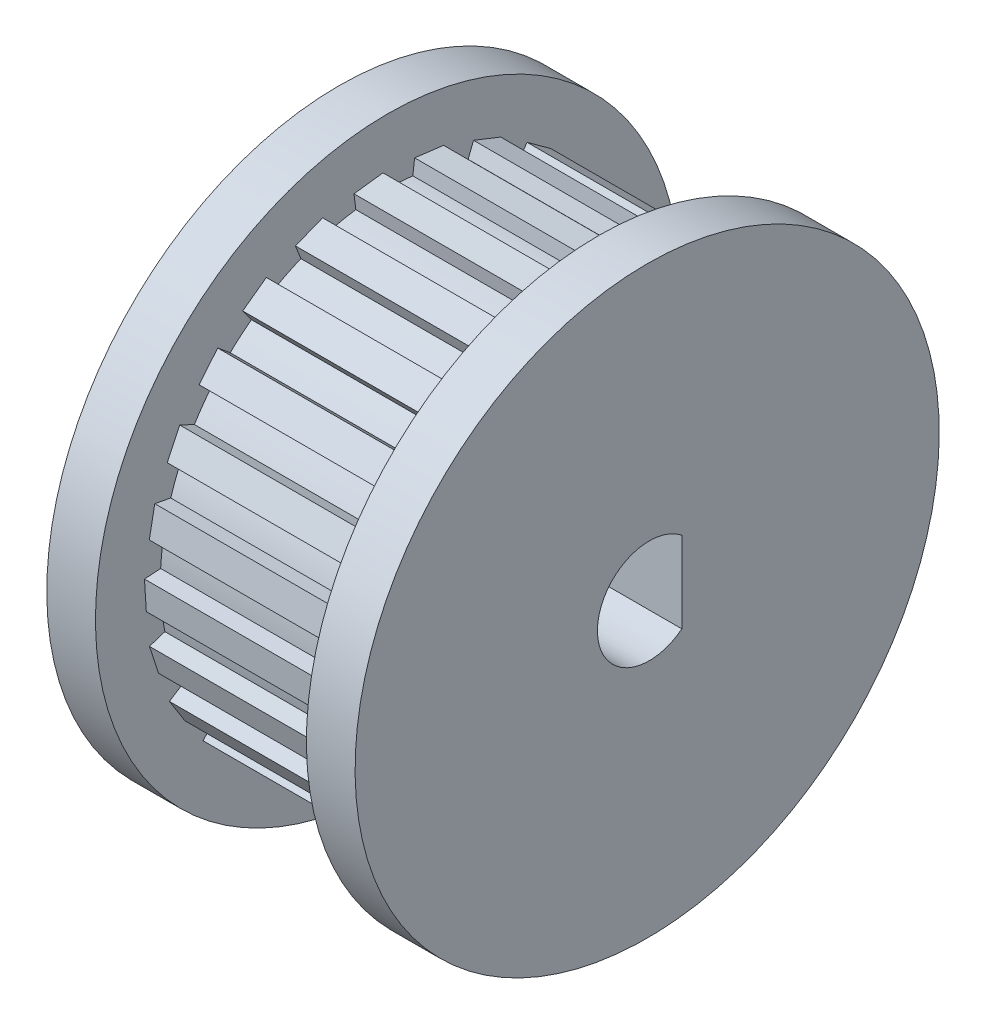
from build123d import *

# Parameters (mm, degrees)
BOSS_EXTRUDE1_DEPTH = 6.5
CUT_EXTRUDE1_DEPTH  = 9.5


with BuildPart() as part:
    # Sketch1 → Revolve1 (revolve)
    with BuildSketch(Plane(origin=(0, 158.016793392, -65.84033058), x_dir=(1, 0, 0), z_dir=(0, 0.923076923, -0.384615385))):
        Polygon((-20.075714319, 213.91124457), (-10.575714319, 213.91124457), (-10.575714319, 204.91124457), (-12.075714319, 204.91124457), (-12.075714319, 206.91124457), (-18.575714319, 206.91124457), (-18.575714319, 204.91124457), (-20.075714319, 204.91124457), align=None)
    revolve(axis=Axis((-11.075714319, 75.743237788, -263.296864029), (-1, 0, 0)))

    # Sketch2 → Boss-Extrude1 (add)
    with BuildSketch(Plane(origin=(-18.575714319, 0, 0), x_dir=(0, 0, -1), z_dir=(1, 0, 0))):
        with BuildLine():
            Line((263.396864029, 68.74395211), (263.396864029, 68.289102327))
            Line((263.396864029, 68.289102327), (262.496864029, 68.289102327))
            Line((262.496864029, 68.289102327), (262.496864029, 68.789102327))
            ThreePointArc((262.496864029, 68.789102327), (262.946136734, 68.752029711), (263.396864029, 68.74395211))
        make_face()
        with BuildLine():
            Line((261.65307078, 68.938978551), (261.539954239, 68.498418711))
            Line((261.539954239, 68.498418711), (260.668229394, 68.72223961))
            Line((260.668229394, 68.72223961), (260.792574337, 69.20653119))
            ThreePointArc((260.792574337, 69.20653119), (261.218512729, 69.058893701), (261.65307078, 68.938978551))
        make_face()
        with BuildLine():
            Line((260.012563106, 69.561541625), (259.793437552, 69.162953722))
            Line((259.793437552, 69.162953722), (259.00476154, 69.596532029))
            Line((259.00476154, 69.596532029), (259.245638377, 70.034685369))
            ThreePointArc((259.245638377, 70.034685369), (259.621479181, 69.785759612), (260.012563106, 69.561541625))
        make_face()
        with BuildLine():
            Line((258.578420138, 70.572523404), (258.267054035, 70.240952182))
            Line((258.267054035, 70.240952182), (257.610982271, 70.857044577))
            Line((257.610982271, 70.857044577), (257.953255824, 71.221528891))
            ThreePointArc((257.953255824, 71.221528891), (258.255383579, 70.886955787), (258.578420138, 70.572523404))
        make_face()
        with BuildLine():
            Line((257.440754352, 71.908400183), (257.056711979, 71.664679482))
            Line((257.056711979, 71.664679482), (256.574467864, 72.424574615))
            Line((256.574467864, 72.424574615), (256.996631826, 72.692488013))
            ThreePointArc((256.996631826, 72.692488013), (257.206062735, 72.293290021), (257.440754352, 71.908400183))
        make_face()
        with BuildLine():
            Line((256.671049475, 73.485233913), (256.238461626, 73.3446776))
            Line((256.238461626, 73.3446776), (255.960346331, 74.200628465))
            Line((255.960346331, 74.200628465), (256.435874589, 74.355136962))
            ThreePointArc((256.435874589, 74.355136962), (256.539449337, 73.91639716), (256.671049475, 73.485233913))
        make_face()
        with BuildLine():
            Line((256.317668895, 75.203946331), (255.863716654, 75.175386077))
            Line((255.863716654, 75.175386077), (255.807205187, 76.073610132))
            Line((255.807205187, 76.073610132), (256.306218551, 76.105005392))
            ThreePointArc((256.306218551, 76.105005392), (256.297429156, 75.654291415), (256.317668895, 75.203946331))
        make_face()
        with BuildLine():
            Line((256.402816812, 76.956544414), (255.95602367, 77.041774764))
            Line((255.95602367, 77.041774764), (256.124666853, 77.92583329))
            Line((256.124666853, 77.92583329), (256.615810478, 77.832142633))
            ThreePointArc((256.615810478, 77.832142633), (256.49520921, 77.397774498), (256.402816812, 76.956544414))
        make_face()
        with BuildLine():
            Line((256.921143071, 78.63290598), (256.509582683, 78.826571598))
            Line((256.509582683, 78.826571598), (256.892784045, 79.640915945))
            Line((256.892784045, 79.640915945), (257.345197571, 79.428026299))
            ThreePointArc((257.345197571, 79.428026299), (257.120362252, 79.037296954), (256.921143071, 78.63290598))
        make_face()
        with BuildLine():
            Line((257.840079325, 80.127699066), (257.489611545, 80.417631229))
            Line((257.489611545, 80.417631229), (258.063293135, 81.111093147))
            Line((258.063293135, 81.111093147), (258.448549757, 80.792381152))
            ThreePointArc((258.448549757, 80.792381152), (258.133607615, 80.469841558), (257.840079325, 80.127699066))
        make_face()
        with BuildLine():
            Line((259.101885432, 81.347000324), (258.834531438, 81.714981528))
            Line((258.834531438, 81.714981528), (259.562646733, 82.243988255))
            Line((259.562646733, 82.243988255), (259.856539359, 81.839479758))
            ThreePointArc((259.856539359, 81.839479758), (259.471279368, 81.605396264), (259.101885432, 81.347000324))
        make_face()
        with BuildLine():
            Line((260.627277471, 82.214196574), (260.459836099, 82.637105206))
            Line((260.459836099, 82.637105206), (261.296634936, 82.968417303))
            Line((261.296634936, 82.968417303), (261.480697212, 82.50352906))
            ThreePointArc((261.480697212, 82.50352906), (261.049326675, 82.372609993), (260.627277471, 82.214196574))
        make_face()
        with BuildLine():
            Line((262.320409452, 82.674798684), (262.263401658, 83.12606184))
            Line((262.263401658, 83.12606184), (263.15630489, 83.23886175))
            Line((263.15630489, 83.23886175), (263.218971506, 82.7428044))
            ThreePointArc((263.218971506, 82.7428044), (262.76859502, 82.723275886), (262.320409452, 82.674798684))
        make_face()
        with BuildLine():
            Line((264.074895666, 82.699865331), (264.13190346, 83.151128487))
            Line((264.13190346, 83.151128487), (265.024806691, 83.038328577))
            Line((265.024806691, 83.038328577), (264.962140074, 82.542271226))
            ThreePointArc((264.962140074, 82.542271226), (264.52105645, 82.635360314), (264.074895666, 82.699865331))
        make_face()
        with BuildLine():
            Line((265.78049529, 82.287821484), (265.947936663, 82.710730117))
            Line((265.947936663, 82.710730117), (266.7847355, 82.379418019))
            Line((266.7847355, 82.379418019), (266.600673224, 81.914529776))
            ThreePointArc((266.600673224, 81.914529776), (266.196597367, 82.114387336), (265.78049529, 82.287821484))
        make_face()
        with BuildLine():
            Line((267.330039228, 81.464557375), (267.597393222, 81.832538579))
            Line((267.597393222, 81.832538579), (268.325508517, 81.303531852))
            Line((268.325508517, 81.303531852), (268.031615891, 80.899023354))
            ThreePointArc((268.031615891, 80.899023354), (267.689937374, 81.193091601), (267.330039228, 81.464557375))
        make_face()
        with BuildLine():
            Line((268.626163935, 80.281801714), (268.976631716, 80.571733877))
            Line((268.976631716, 80.571733877), (269.550313307, 79.878271959))
            Line((269.550313307, 79.878271959), (269.165056685, 79.559559964))
            ThreePointArc((269.165056685, 79.559559964), (268.907244427, 79.929361507), (268.626163935, 80.281801714))
        make_face()
        with BuildLine():
            Line((269.587429129, 78.81387139), (269.998989517, 79.007537008))
            Line((269.998989517, 79.007537008), (270.38219088, 78.193192661))
            Line((270.38219088, 78.193192661), (269.929777353, 77.980303015))
            ThreePointArc((269.929777353, 77.980303015), (269.772030645, 78.402601865), (269.587429129, 78.81387139))
        make_face()
        with BuildLine():
            Line((270.153434983, 77.153001864), (270.600228126, 77.238232214))
            Line((270.600228126, 77.238232214), (270.768871309, 76.354173689))
            Line((270.768871309, 76.354173689), (270.277727683, 76.260483031))
            ThreePointArc((270.277727683, 76.260483031), (270.229958331, 76.708744597), (270.153434983, 77.153001864))
        make_face()
        with BuildLine():
            Line((270.288617268, 75.403551676), (270.742569508, 75.374991422))
            Line((270.742569508, 75.374991422), (270.68605804, 74.476767367))
            Line((270.68605804, 74.476767367), (270.187044676, 74.508162626))
            ThreePointArc((270.187044676, 74.508162626), (270.252254204, 74.954220986), (270.288617268, 75.403551676))
        make_face()
        with BuildLine():
            Line((269.984481982, 73.675445216), (270.417069832, 73.534888904))
            Line((270.417069832, 73.534888904), (270.138954537, 72.678938039))
            Line((270.138954537, 72.678938039), (269.663426278, 72.833446536))
            ThreePointArc((269.663426278, 72.833446536), (269.837517332, 73.249274201), (269.984481982, 73.675445216))
        make_face()
        with BuildLine():
            Line((269.260139065, 72.077265768), (269.644181438, 71.833545067))
            Line((269.644181438, 71.833545067), (269.161937323, 71.073649934))
            Line((269.161937323, 71.073649934), (268.73977336, 71.341563332))
            ThreePointArc((268.73977336, 71.341563332), (269.011807158, 71.701032322), (269.260139065, 72.077265768))
        make_face()
        with BuildLine():
            Line((268.161101646, 70.709432825), (268.472467748, 70.377861603))
            Line((268.472467748, 70.377861603), (267.816395984, 69.761769208))
            Line((267.816395984, 69.761769208), (267.474122431, 70.126253522))
            ThreePointArc((267.474122431, 70.126253522), (267.82700609, 70.406777078), (268.161101646, 70.709432825))
        make_face()
        with BuildLine():
            Line((266.756426289, 69.65789236), (266.975551842, 69.259304457))
            Line((266.975551842, 69.259304457), (266.18687583, 68.825726151))
            Line((266.18687583, 68.825726151), (265.945998993, 69.263879491))
            ThreePointArc((265.945998993, 69.263879491), (266.357559535, 69.447831286), (266.756426289, 69.65789236))
        make_face()
        with BuildLine():
            Line((265.134373911, 68.988716529), (265.247490452, 68.548156689))
            Line((265.247490452, 68.548156689), (264.375765607, 68.32433579))
            Line((264.375765607, 68.32433579), (264.251420663, 68.808627371))
            ThreePointArc((264.251420663, 68.808627371), (264.695798225, 68.884449038), (265.134373911, 68.988716529))
        make_face()
    extrude(amount=BOSS_EXTRUDE1_DEPTH)

    # Sketch3 → Cut-Extrude1 (cut)
    with BuildSketch(Plane(origin=(-10.575714319, 0, 0), x_dir=(0, 0, -1), z_dir=(1, 0, 0))):
        with BuildLine():
            Line((264.364668647, 74.465986264), (264.364668647, 76.963985463))
            ThreePointArc((264.364668647, 76.963985463), (261.764668647, 75.714985864), (264.364668647, 74.465986264))
        make_face()
    extrude(amount=-CUT_EXTRUDE1_DEPTH, mode=Mode.SUBTRACT)


solid = part.part
